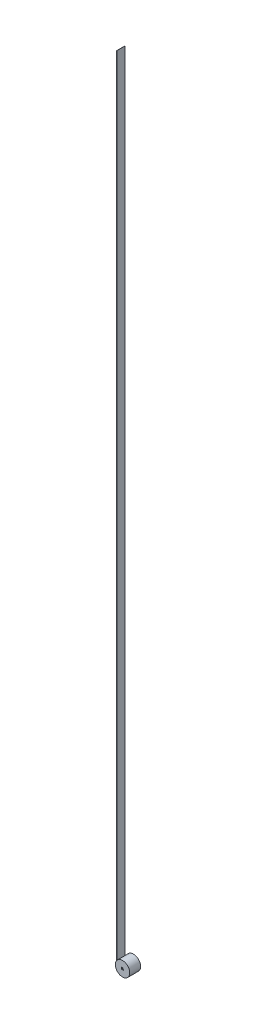
from build123d import *

# Parameters (mm, degrees)
SKETCH1_R           = 28.25
BOSS_EXTRUDE1_DEPTH = 43
SKETCH4_W           = 0.4
SKETCH4_H           = 31.75
BOSS_EXTRUDE2_DEPTH = 3106
SKETCH6_W           = 8
SKETCH6_H           = 8
CUT_EXTRUDE1_DEPTH  = 3.5


with BuildPart() as part:
    # Sketch1 → Boss-Extrude1 (new body)
    with BuildSketch(Plane.XY):
        Circle(SKETCH1_R)
    extrude(amount=BOSS_EXTRUDE1_DEPTH)

    # Sketch6 → Cut-Extrude1 (cut)
    with BuildSketch(Plane.XY.offset(43)):
        Rectangle(SKETCH6_W, SKETCH6_H)
    extrude(amount=-CUT_EXTRUDE1_DEPTH, mode=Mode.SUBTRACT)


with BuildPart() as body_2:
    # Sketch4 → Boss-Extrude2 (new body)
    with BuildSketch(Plane(origin=(0, 0, 0), x_dir=(1, 0, 0), z_dir=(0, 1, 0))):
        with Locations((-28.45, -21.5)):
            Rectangle(SKETCH4_W, SKETCH4_H)
    extrude(amount=BOSS_EXTRUDE2_DEPTH)


solid = Compound([part.part, body_2.part])
